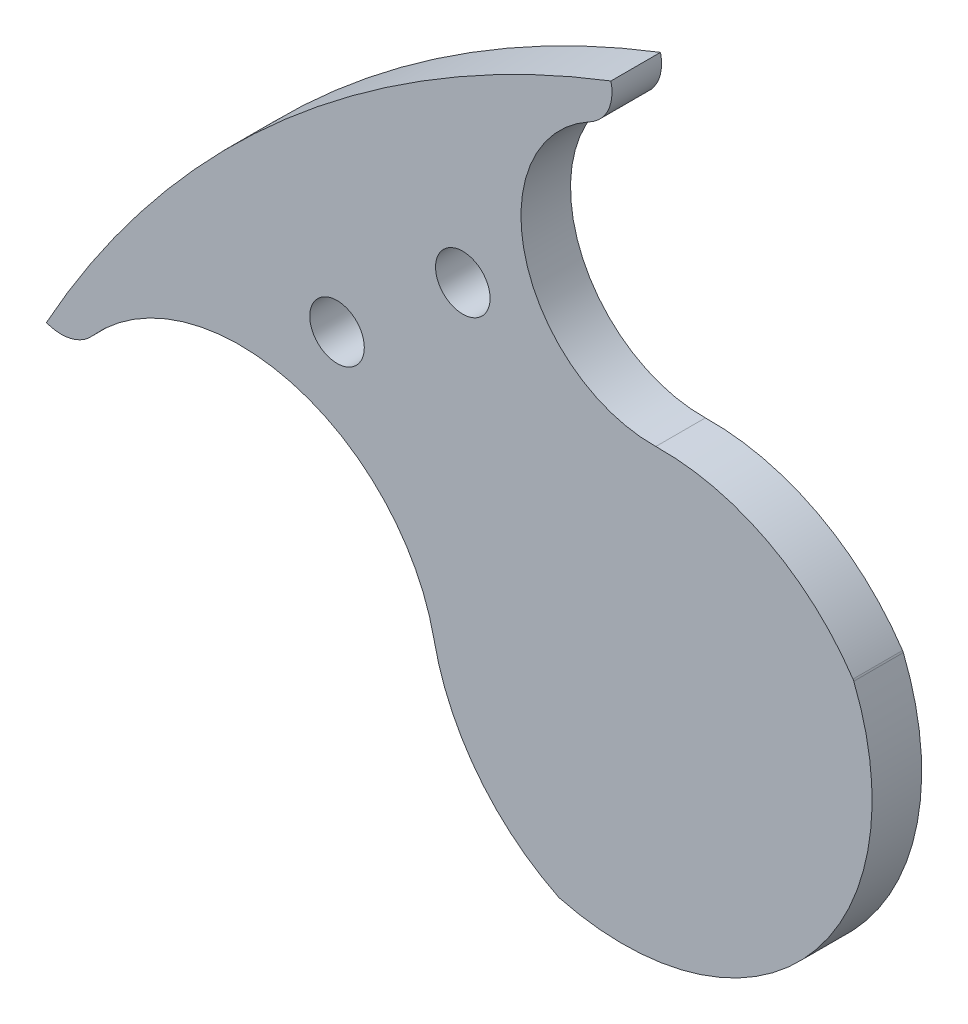
from build123d import *

# Parameters (mm, degrees)
BOSS_EXTRUDE1_DEPTH = 3
SKETCH4_R           = 1.65
CUT_EXTRUDE1_DEPTH  = 85.697107


with BuildPart() as part:
    # Sketch5 → Boss-Extrude1 (new body)
    with BuildSketch(Plane(origin=(0, 0, 0), x_dir=(0, 1, 0), z_dir=(0, 0, 1))):
        with BuildLine():
            ThreePointArc((37.723245901, 9.079766174), (42.363354518, 14.24854402), (43.948073482, 21.011349518))
            ThreePointArc((43.948073482, 21.011349518), (49.906664226, 28.911044217), (58.985716635, 24.976481046))
            ThreePointArc((58.985716635, 24.976481046), (60.156028849, 23.886109344), (61.747774642, 23.728354912))
            ThreePointArc((61.747774642, 23.728354912), (49.889938389, 43.437501627), (32.000159984, 57.894837948))
            ThreePointArc((32.000159984, 57.894837948), (31.906399176, 56.411758551), (32.670933348, 55.137473226))
            ThreePointArc((32.670933348, 55.137473226), (36.27043514, 43.073301984), (27.113180378, 34.433549317))
            ThreePointArc((27.113180378, 34.433549317), (21.388023687, 31.800064681), (17.397863538, 26.922433858))
            ThreePointArc((17.397863538, 26.922433858), (17.377786203, 26.87598895), (17.362505758, 26.82775269))
            ThreePointArc((17.362505758, 26.82775269), (22.00306193, 11.670310925), (37.63394302, 9.032440796))
            ThreePointArc((37.63394302, 9.032440796), (37.679793297, 9.053841282), (37.723245901, 9.079766174))
        make_face()
    extrude(amount=BOSS_EXTRUDE1_DEPTH)

    # Sketch4 → Cut-Extrude1 (cut, through all)
    with BuildSketch(Plane(origin=(0, 0, 0), x_dir=(0, 1, 0), z_dir=(0, 0, 1))):
        with Locations((40.305086528, 40.305086528)):
            Circle(SKETCH4_R)
        with Locations((46.691666524, 32.693856872)):
            Circle(SKETCH4_R)
    extrude(amount=CUT_EXTRUDE1_DEPTH, mode=Mode.SUBTRACT)


solid = part.part
